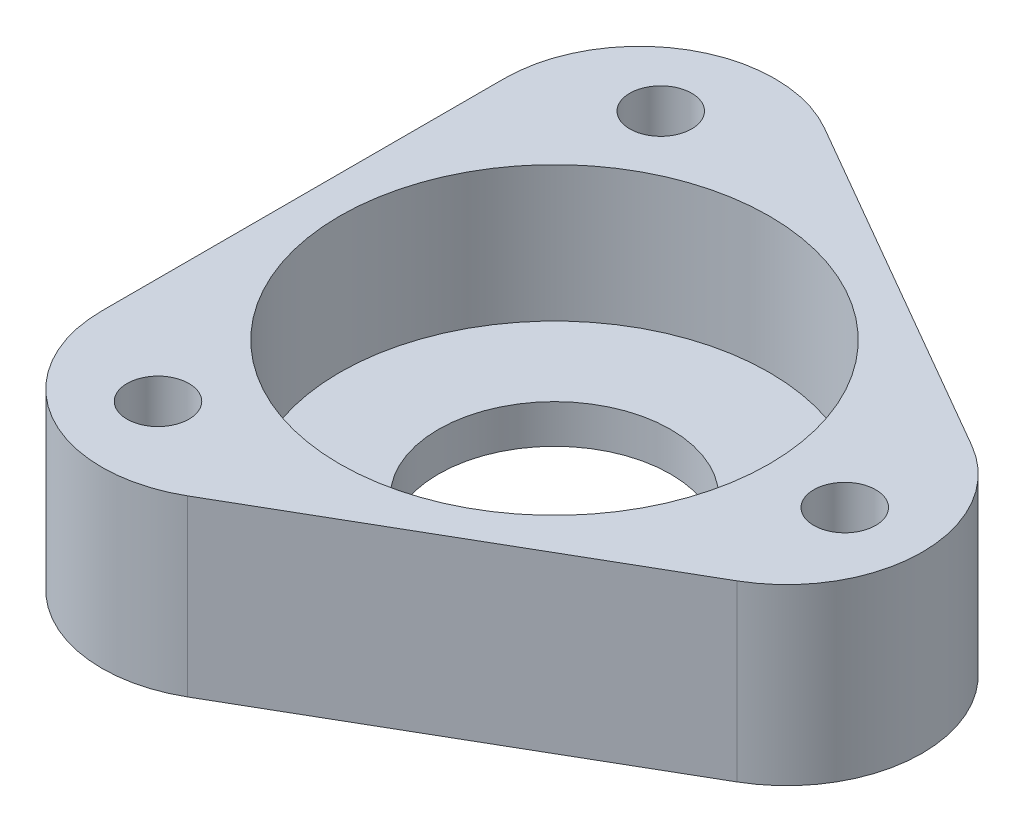
from build123d import *

# Parameters (mm, degrees)
SKETCH1_R           = 1.6
BOSS_EXTRUDE1_DEPTH = 9
SKETCH2_R           = 11.1
CUT_EXTRUDE1_DEPTH  = 7
FILLET1_R           = 7
SKETCH3_R           = 6
CUT_EXTRUDE2_DEPTH  = 3


with BuildPart() as part:
    # Sketch1 → Boss-Extrude1 (new body)
    with BuildSketch(Plane(origin=(0, 0, 0), x_dir=(1, 0, 0), z_dir=(0, 1, 0))):
        Polygon((26, 0), (-13, 22.516660498), (-13, -22.516660498), align=None)
        with Locations((-7.5, 12.990381057)):
            Circle(SKETCH1_R, mode=Mode.SUBTRACT)
        with Locations((15, 0)):
            Circle(SKETCH1_R, mode=Mode.SUBTRACT)
        with Locations((-7.5, -12.990381057)):
            Circle(SKETCH1_R, mode=Mode.SUBTRACT)
    extrude(amount=BOSS_EXTRUDE1_DEPTH)

    # Sketch2 → Cut-Extrude1 (cut)
    with BuildSketch(Plane(origin=(0, 9, 0), x_dir=(1, 0, 0), z_dir=(0, 1, 0))):
        Circle(SKETCH2_R)
    extrude(amount=-CUT_EXTRUDE1_DEPTH, mode=Mode.SUBTRACT)

    # Fillet1
    fillet1_edges = [part.edges().sort_by_distance(p)[0] for p in [
        (-13, 4.5, 22.516660498),
        (-13, 4.5, -22.516660498),
        (26, 4.5, 0),
    ]]
    fillet(fillet1_edges, radius=FILLET1_R)

    # Sketch3 → Cut-Extrude2 (cut, through all)
    with BuildSketch(Plane(origin=(0, 2, 0), x_dir=(1, 0, 0), z_dir=(0, 1, 0))):
        Circle(SKETCH3_R)
    extrude(amount=-CUT_EXTRUDE2_DEPTH, mode=Mode.SUBTRACT)


solid = part.part
